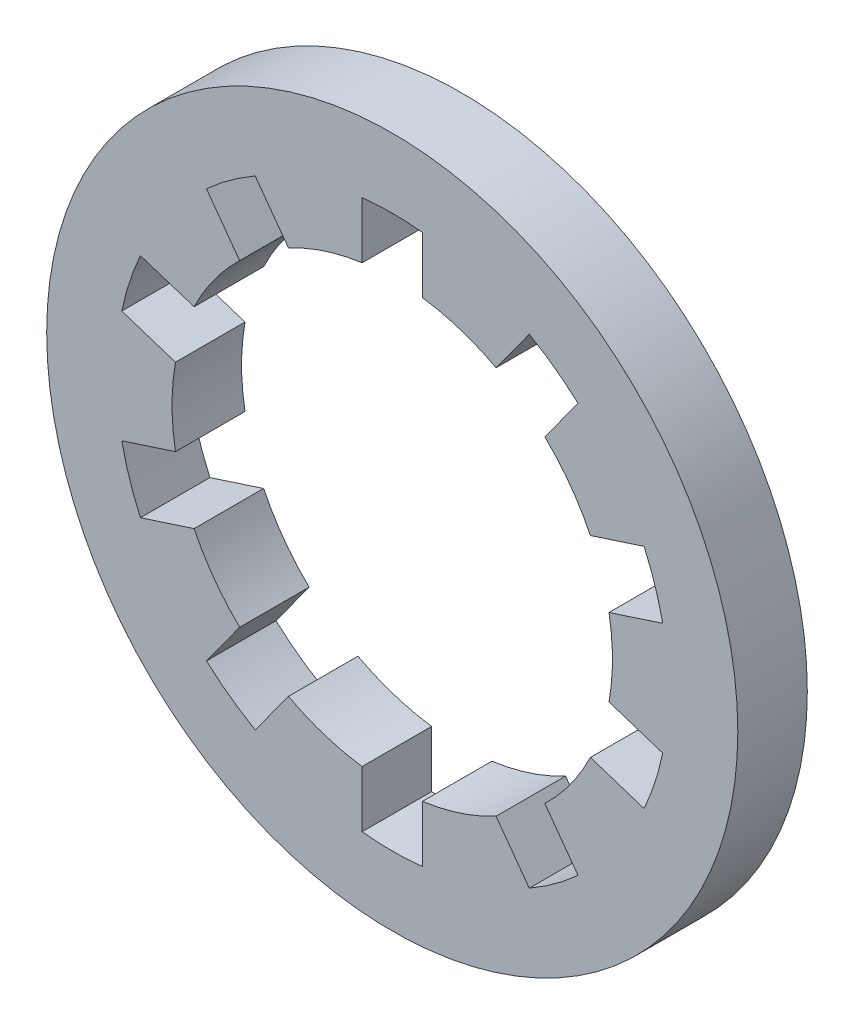
from build123d import *

# Parameters (mm, degrees)
SZKIC1_R                    = 8.6
DODANIE_WYCI_GNI_CIE1_DEPTH = 1.73
WYTNIJ_WYCI_GNI_CIE1_DEPTH  = 1.73


with BuildPart() as part:
    # Szkic1 → Dodanie-wyciągnięcie1 (new body)
    with BuildSketch(Plane.XY):
        Circle(SZKIC1_R)
    extrude(amount=DODANIE_WYCI_GNI_CIE1_DEPTH)

    # Szkic2 → Wytnij-wyciągnięcie1 (cut)
    with BuildSketch(Plane.XY.offset(1.73)):
        with BuildLine():
            Line((-2.583990936, 4.832534619), (-3.410143133, 5.969635568))
            ThreePointArc((-3.410143133, 5.969635568), (-4.04102361, 5.561991836), (-4.623668625, 5.087957689))
            Line((-4.623668625, 5.087957689), (-3.797516427, 3.950856741))
            ThreePointArc((-3.797516427, 3.950856741), (-4.433413129, 3.221063183), (-4.930985161, 2.390770869))
            Line((-4.930985161, 2.390770869), (-6.267727496, 2.825104782))
            ThreePointArc((-6.267727496, 2.825104782), (-6.53851355, 2.124491836), (-6.731252988, 1.398520008))
            Line((-6.731252988, 1.398520008), (-5.394510652, 0.964186094))
            ThreePointArc((-5.394510652, 0.964186094), (-5.48, 0), (-5.394510652, -0.964186094))
            Line((-5.394510652, -0.964186094), (-6.731252988, -1.398520008))
            ThreePointArc((-6.731252988, -1.398520008), (-6.53851355, -2.124491836), (-6.267727496, -2.825104782))
            Line((-6.267727496, -2.825104782), (-4.930985161, -2.390770869))
            ThreePointArc((-4.930985161, -2.390770869), (-4.433413129, -3.221063183), (-3.797516427, -3.950856741))
            Line((-3.797516427, -3.950856741), (-4.623668625, -5.087957689))
            ThreePointArc((-4.623668625, -5.087957689), (-4.04102361, -5.561991836), (-3.410143133, -5.969635568))
            Line((-3.410143133, -5.969635568), (-2.583990936, -4.832534619))
            ThreePointArc((-2.583990936, -4.832534619), (-1.693413129, -5.211789709), (-0.75, -5.428434397))
            Line((-0.75, -5.428434397), (-0.75, -6.833968466))
            ThreePointArc((-0.75, -6.833968466), (0, -6.875), (0.75, -6.833968466))
            Line((0.75, -6.833968466), (0.75, -5.428434397))
            ThreePointArc((0.75, -5.428434397), (1.693413129, -5.211789709), (2.583990936, -4.832534619))
            Line((2.583990936, -4.832534619), (3.410143133, -5.969635568))
            ThreePointArc((3.410143133, -5.969635568), (4.04102361, -5.561991836), (4.623668625, -5.087957689))
            Line((4.623668625, -5.087957689), (3.797516427, -3.950856741))
            ThreePointArc((3.797516427, -3.950856741), (4.433413129, -3.221063183), (4.930985161, -2.390770869))
            Line((4.930985161, -2.390770869), (6.267727496, -2.825104782))
            ThreePointArc((6.267727496, -2.825104782), (6.53851355, -2.124491836), (6.731252988, -1.398520008))
            Line((6.731252988, -1.398520008), (5.394510652, -0.964186094))
            ThreePointArc((5.394510652, -0.964186094), (5.48, 0), (5.394510652, 0.964186094))
            Line((5.394510652, 0.964186094), (6.731252988, 1.398520008))
            ThreePointArc((6.731252988, 1.398520008), (6.53851355, 2.124491836), (6.267727496, 2.825104782))
            Line((6.267727496, 2.825104782), (4.930985161, 2.390770869))
            ThreePointArc((4.930985161, 2.390770869), (4.433413129, 3.221063183), (3.797516427, 3.950856741))
            Line((3.797516427, 3.950856741), (4.623668625, 5.087957689))
            ThreePointArc((4.623668625, 5.087957689), (4.04102361, 5.561991836), (3.410143133, 5.969635568))
            Line((3.410143133, 5.969635568), (2.583990936, 4.832534619))
            ThreePointArc((2.583990936, 4.832534619), (1.693413129, 5.211789709), (0.75, 5.428434397))
            Line((0.75, 5.428434397), (0.75, 6.833968466))
            ThreePointArc((0.75, 6.833968466), (0, 6.875), (-0.75, 6.833968466))
            Line((-0.75, 6.833968466), (-0.75, 5.428434397))
            ThreePointArc((-0.75, 5.428434397), (-1.693413129, 5.211789709), (-2.583990936, 4.832534619))
        make_face()
    extrude(amount=-WYTNIJ_WYCI_GNI_CIE1_DEPTH, mode=Mode.SUBTRACT)


solid = part.part
